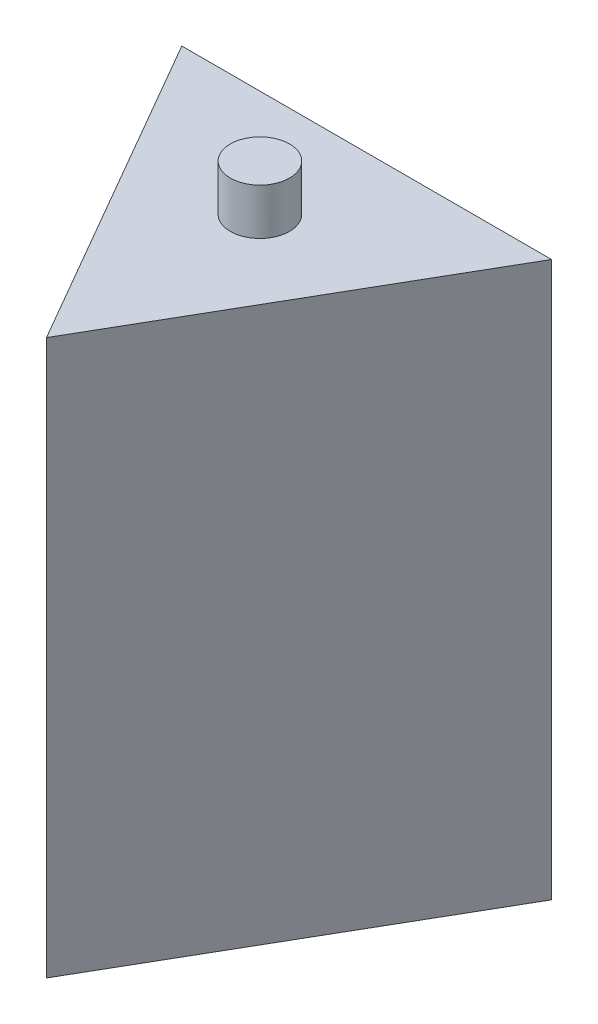
from build123d import *

# Parameters (mm, degrees)
BOSS_EXTRUDE1_DEPTH = 76.2
SKETCH3_R           = 4.064
BOSS_EXTRUDE2_DEPTH = 6.35
SKETCH2_W           = 25.4
SKETCH2_H           = 6.35
CUT_EXTRUDE2_DEPTH  = 25.4


with BuildPart() as part:
    # Sketch1 → Boss-Extrude1 (new body)
    with BuildSketch(Plane(origin=(0, 0, 0), x_dir=(1, 0, 0), z_dir=(0, 1, 0))):
        Polygon((0, 0), (-25.4, 43.994090512), (25.4, 43.994090512), align=None)
    extrude(amount=BOSS_EXTRUDE1_DEPTH)

    # Sketch3 → Boss-Extrude2 (add)
    with BuildSketch(Plane(origin=(0, 76.2, 0), x_dir=(1, 0, 0), z_dir=(0, 1, 0))):
        with Locations((0, 29.329393675)):
            Circle(SKETCH3_R)
    extrude(amount=BOSS_EXTRUDE2_DEPTH)

    # Sketch2 → Cut-Extrude2 (cut)
    with BuildSketch(Plane(origin=(0, 0, 0), x_dir=(1, 0, 0), z_dir=(0, 1, 0))):
        with Locations((0, 29.329393675)):
            Rectangle(SKETCH2_W, SKETCH2_H)
    extrude(amount=CUT_EXTRUDE2_DEPTH, mode=Mode.SUBTRACT)


solid = part.part
